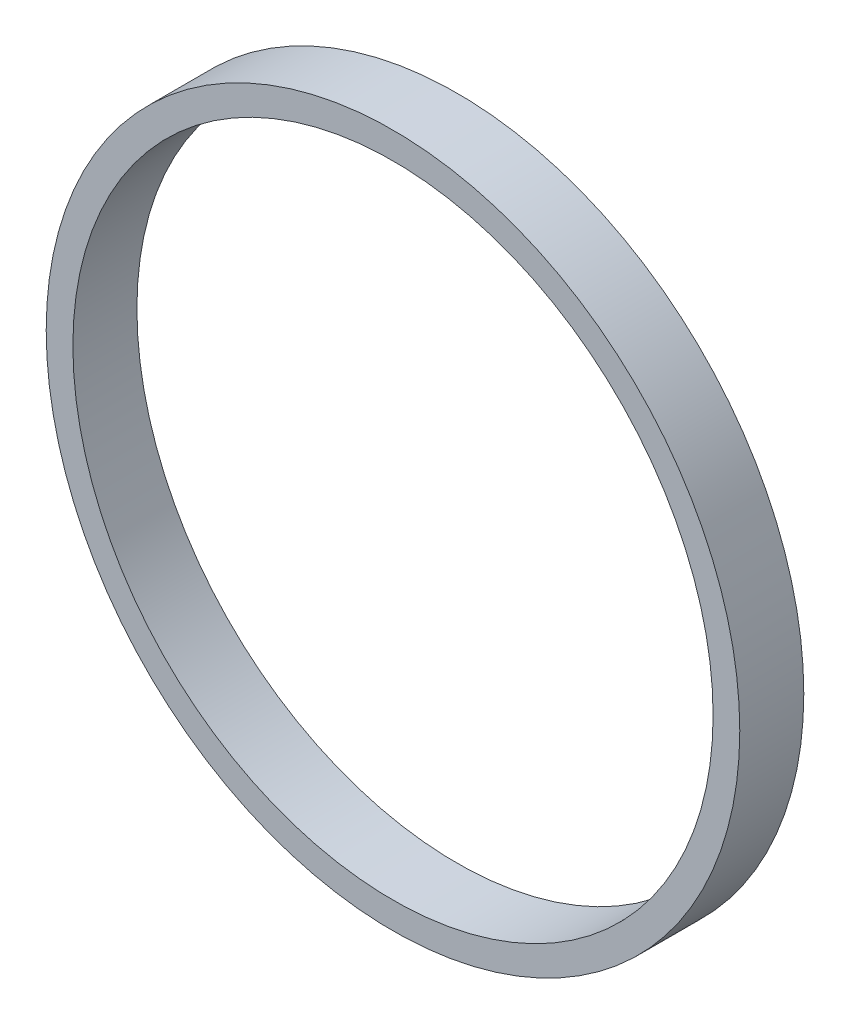
from build123d import *

# Parameters (mm, degrees)
SKETCH1_R           = 32.5
SKETCH1_R_2         = 30
BOSS_EXTRUDE1_DEPTH = 3


with BuildPart() as part:
    # Sketch1 → Boss-Extrude1 (new body, symmetric)
    with BuildSketch(Plane.XY):
        Circle(SKETCH1_R)
        Circle(SKETCH1_R_2, mode=Mode.SUBTRACT)
    extrude(amount=BOSS_EXTRUDE1_DEPTH, both=True)


solid = part.part
